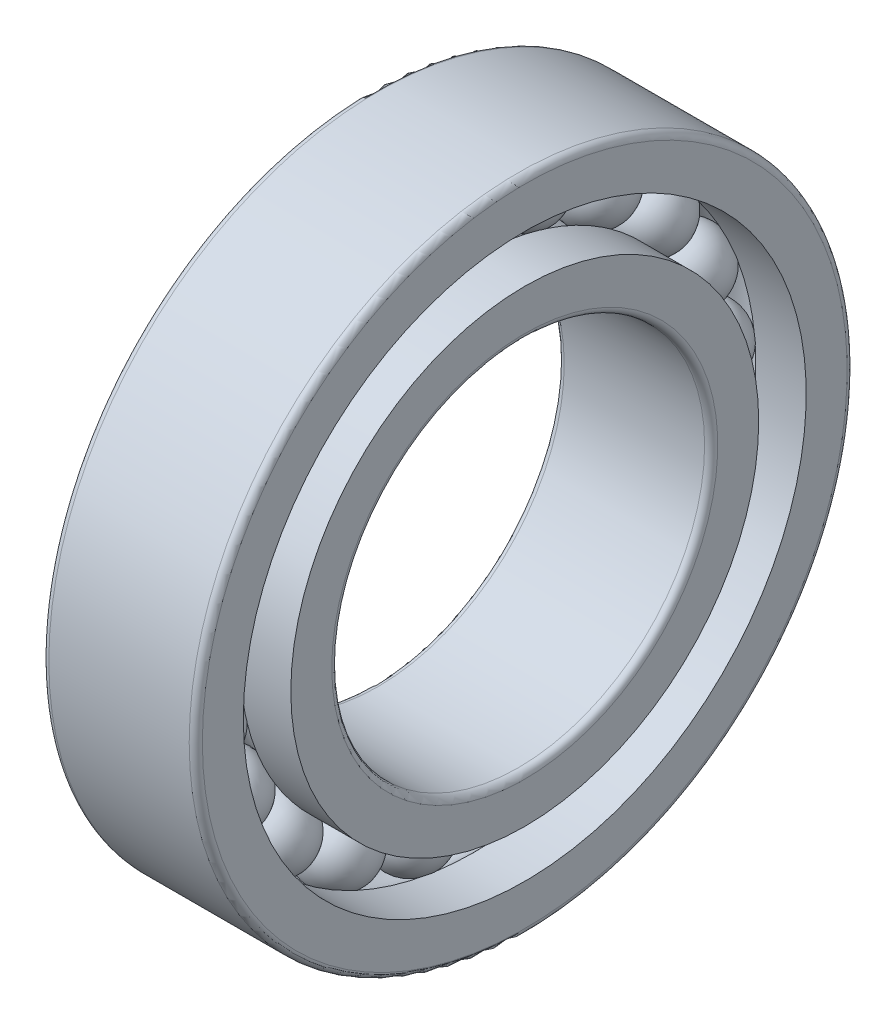
from build123d import *

# Parameters (mm, degrees)
CIRCULAR_PATTERN1_COUNT = 21
FILLET1_R               = 0.3


with BuildPart() as part:
    # Sketch1 → Revolve1 (revolve)
    with BuildSketch(Plane.XY):
        with BuildLine():
            Line((-1.625, 11.75), (1.625, 11.75))
            ThreePointArc((1.625, 11.75), (0, 13.375), (-1.625, 11.75))
        make_face()
    revolve1 = revolve(axis=Axis((-4.596601835, 11.75, 0), (1, 0, 0)))

    # Sketch2 → Revolve2 (revolve)
    with BuildSketch(Plane.XY, mode=Mode.PRIVATE) as revolve2_sk:
        with BuildLine():
            Line((-3.5, 10.666666667), (-3.5, 8.5))
            Line((-3.5, 8.5), (3.5, 8.5))
            Line((3.5, 8.5), (3.5, 10.666666667))
            Line((3.5, 10.666666667), (1.197753685, 10.666666667))
            ThreePointArc((1.197753685, 10.666666667), (0, 10.135), (-1.197753685, 10.666666667))
            Line((-1.197753685, 10.666666667), (-3.5, 10.666666667))
        make_face()
    revolve(revolve2_sk.sketch.rotate(Axis((-6.971390126, 0, 0), (1, 0, 0)), 90), axis=Axis((-6.971390126, 0, 0), (1, 0, 0)))

    # Sketch3 → Revolve3 (revolve)
    with BuildSketch(Plane.XY, mode=Mode.PRIVATE) as revolve3_sk:
        with BuildLine():
            Line((-3.5, 15), (3.5, 15))
            Line((3.5, 15), (3.5, 12.833333333))
            Line((3.5, 12.833333333), (1.197753685, 12.833333333))
            ThreePointArc((1.197753685, 12.833333333), (0, 13.365), (-1.197753685, 12.833333333))
            Line((-1.197753685, 12.833333333), (-3.5, 12.833333333))
            Line((-3.5, 12.833333333), (-3.5, 15))
        make_face()
    revolve(revolve3_sk.sketch.rotate(Axis((-8.710676495, 0, 0), (1, 0, 0)), 90), axis=Axis((-8.710676495, 0, 0), (1, 0, 0)))

    # Circular-Pattern1: Revolve1 ×21 about axis
    circular_pattern1_axis = Axis((0, 0, 0), (1, 0, 0))
    for i in range(1, CIRCULAR_PATTERN1_COUNT):
        add(revolve1.rotate(circular_pattern1_axis, i * 360 / CIRCULAR_PATTERN1_COUNT))

    # Fillet1
    fillet1_edges = [part.edges().sort_by_distance(p)[0] for p in [
        (-3.5, 0, -15),
        (3.5, 0, -15),
        (-3.5, 0, -8.5),
        (3.5, 0, -8.5),
    ]]
    fillet(fillet1_edges, radius=FILLET1_R)


solid = part.part
